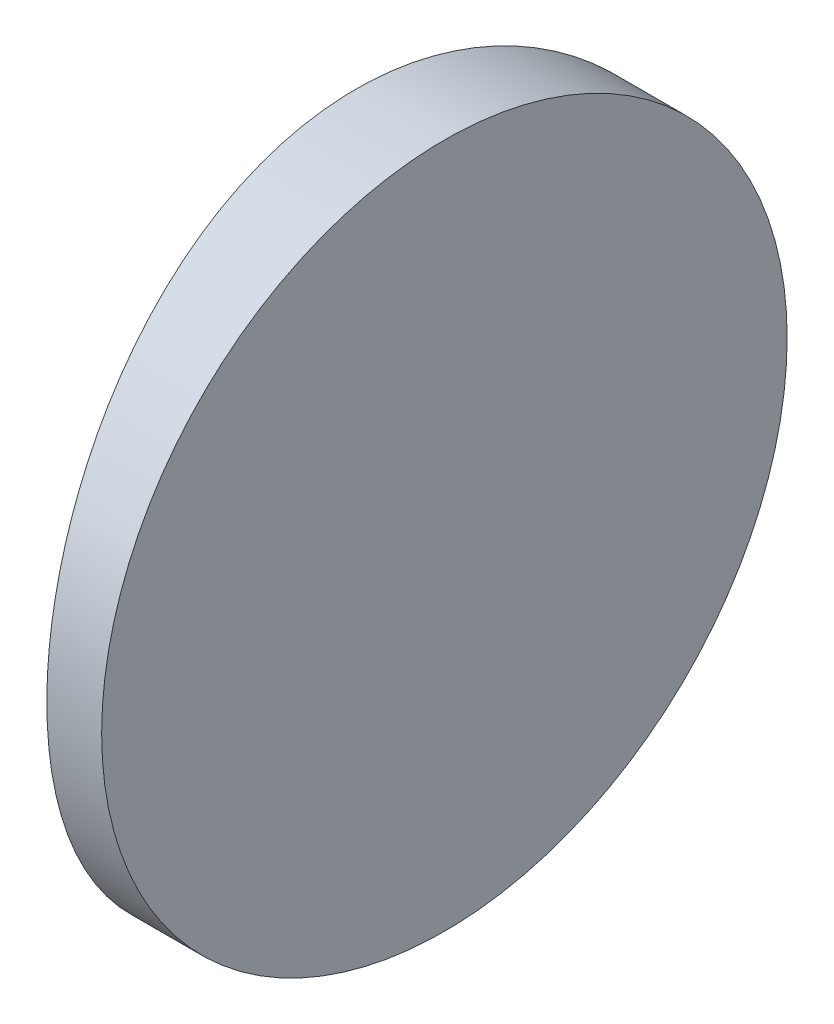
from build123d import *

# Parameters (mm, degrees)
EXTRUDE_1_DEPTH     = 25
CUT_EXTRUDE_8_DEPTH = 12.7


with BuildPart() as part:
    # 草图1 → 凸台-拉伸1 (new body)
    with BuildSketch(Plane(origin=(0, 0, 0), x_dir=(1, 0, 0), z_dir=(0, 1, 0))):
        with BuildLine():
            Line((-59.023893166, 12.5), (-57.024795665, 12.5))
            Line((-57.024795665, 12.5), (-57.024795665, -12.5))
            Line((-57.024795665, -12.5), (-59.023893166, -12.5))
            ThreePointArc((-59.023893166, -12.5), (-60.244795665, 0), (-59.023893166, 12.5))
        make_face()
    extrude(amount=EXTRUDE_1_DEPTH)

    # 草图2 → 切除-拉伸8 (cut)
    with BuildSketch(Plane(origin=(-57.024795665, 0, 0), x_dir=(0, 0, -1), z_dir=(1, 0, 0))):
        with BuildLine():
            Line((-12.5, 25), (-12.5, 12.5))
            ThreePointArc((-12.5, 12.5), (-8.838834765, 21.338834765), (0, 25))
            Line((0, 25), (-12.5, 25))
        make_face()
        with BuildLine():
            ThreePointArc((0, 25), (8.838834765, 21.338834765), (12.5, 12.5))
            Line((12.5, 12.5), (12.5, 25))
            Line((12.5, 25), (0, 25))
        make_face()
        with BuildLine():
            ThreePointArc((12.5, 12.5), (8.838834765, 3.661165235), (0, 0))
            Line((0, 0), (12.5, 0))
            Line((12.5, 0), (12.5, 12.5))
        make_face()
        with BuildLine():
            Line((-12.5, 12.5), (-12.5, 0))
            Line((-12.5, 0), (0, 0))
            ThreePointArc((0, 0), (-8.838834765, 3.661165235), (-12.5, 12.5))
        make_face()
    extrude(amount=-CUT_EXTRUDE_8_DEPTH, mode=Mode.SUBTRACT)


solid = part.part
